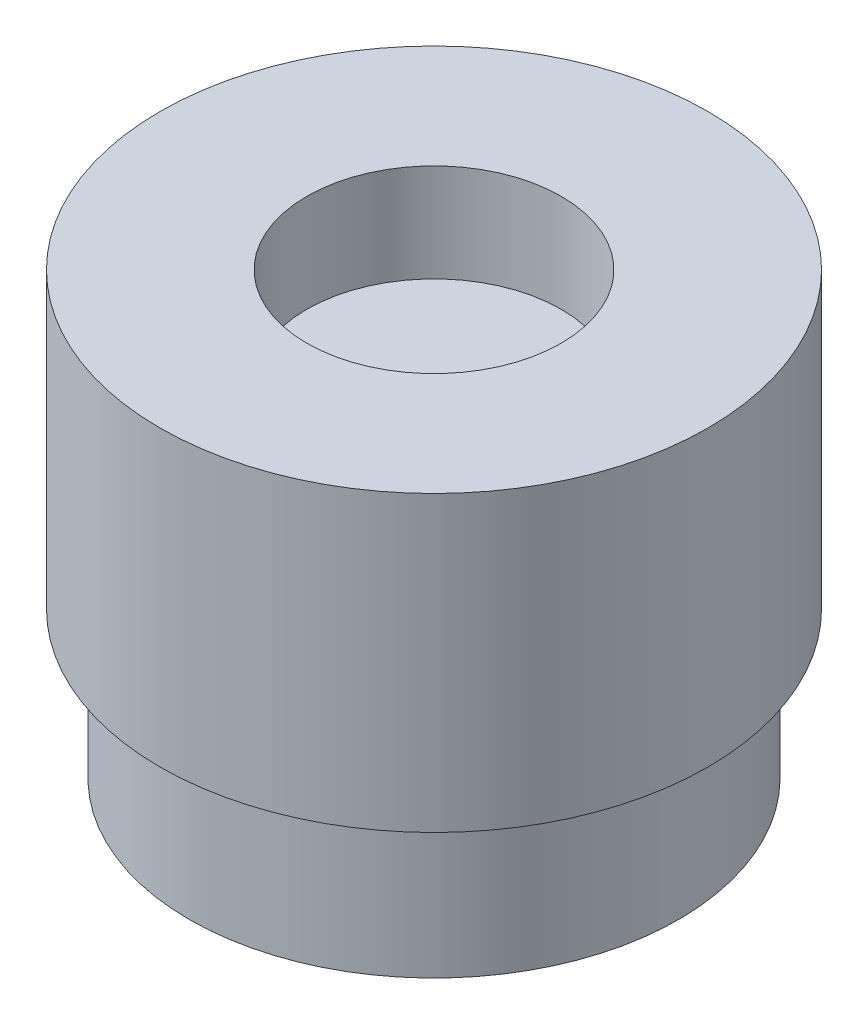
from build123d import *

# Parameters (mm, degrees)
SKETCH1_R           = 5
SKETCH1_R_2         = 1.5
BOSS_EXTRUDE1_DEPTH = 3
SKETCH3_R           = 4.5
SKETCH3_R_2         = 3.75
BOSS_EXTRUDE2_DEPTH = 2.5
SKETCH4_W           = 2
SKETCH4_H           = 1.385791926
CUT_EXTRUDE1_DEPTH  = 2.5
SKETCH5_R           = 5.6
BOSS_EXTRUDE3_DEPTH = 3
SKETCH6_R           = 5.6
BOSS_EXTRUDE4_DEPTH = 1
SKETCH7_R           = 5.6
SKETCH7_R_2         = 2.6
BOSS_EXTRUDE5_DEPTH = 2


with BuildPart() as part:
    # Sketch1 → Boss-Extrude1 (new body)
    with BuildSketch(Plane(origin=(0, 0, 0), x_dir=(1, 0, 0), z_dir=(0, 1, 0))):
        Circle(SKETCH1_R)
        Circle(SKETCH1_R_2, mode=Mode.SUBTRACT)
    extrude(amount=BOSS_EXTRUDE1_DEPTH)

    # Sketch3 → Boss-Extrude2 (add)
    with BuildSketch(Plane(origin=(0, 3, 0), x_dir=(1, 0, 0), z_dir=(0, 1, 0))):
        Circle(SKETCH3_R)
        Circle(SKETCH3_R_2, mode=Mode.SUBTRACT)
    extrude(amount=BOSS_EXTRUDE2_DEPTH)

    # Sketch4 → Cut-Extrude1 (cut)
    with BuildSketch(Plane(origin=(0, 5.5, 0), x_dir=(1, 0, 0), z_dir=(0, 1, 0))):
        with Locations((0, 4.307104037)):
            Rectangle(SKETCH4_W, SKETCH4_H)
    extrude(amount=-CUT_EXTRUDE1_DEPTH, mode=Mode.SUBTRACT)


with BuildPart() as body_2:
    # Sketch5 → Boss-Extrude3 (new body)
    with BuildSketch(Plane(origin=(0, 3, 0), x_dir=(1, 0, 0), z_dir=(0, 1, 0))):
        Circle(SKETCH5_R)
        with BuildLine():
            ThreePointArc((5, 0), (-3.181980515, -3.856812155), (-0.95, 4.908920452))
            Line((-0.95, 4.908920452), (-0.95, 5))
            Line((-0.95, 5), (0, 5))
            Line((0, 5), (0.95, 5))
            Line((0.95, 5), (0.95, 4.908920452))
            ThreePointArc((0.95, 4.908920452), (3.856812155, 3.181980515), (5, 0))
        make_face(mode=Mode.SUBTRACT)
        with BuildLine():
            ThreePointArc((4.6, 0), (-2.897412639, -3.572814017), (-0.95, 4.500833256))
            Line((-0.95, 4.500833256), (-0.95, 4.908920452))
            ThreePointArc((-0.95, 4.908920452), (-3.181980515, -3.856812155), (5, 0))
            ThreePointArc((5, 0), (3.856812155, 3.181980515), (0.95, 4.908920452))
            Line((0.95, 4.908920452), (0.95, 4.500833256))
            ThreePointArc((0.95, 4.500833256), (3.572814017, 2.897412639), (4.6, 0))
        make_face()
        with BuildLine():
            Line((-0.95, 4.908920452), (-0.95, 4.500833256))
            ThreePointArc((-0.95, 4.500833256), (0, 4.6), (0.95, 4.500833256))
            Line((0.95, 4.500833256), (0.95, 4.908920452))
            ThreePointArc((0.95, 4.908920452), (0.477178029, 4.977178029), (0, 5))
            ThreePointArc((0, 5), (-0.477178029, 4.977178029), (-0.95, 4.908920452))
        make_face()
        with BuildLine():
            Line((-0.95, 4.500833256), (-0.95, 3.75))
            Line((-0.95, 3.75), (0, 3.75))
            Line((0, 3.75), (0.95, 3.75))
            Line((0.95, 3.75), (0.95, 4.500833256))
            ThreePointArc((0.95, 4.500833256), (0, 4.6), (-0.95, 4.500833256))
        make_face()
        with BuildLine():
            Line((-0.95, 5), (-0.95, 4.908920452))
            ThreePointArc((-0.95, 4.908920452), (-0.477178029, 4.977178029), (0, 5))
            Line((0, 5), (-0.95, 5))
        make_face()
        with BuildLine():
            Line((0.95, 5), (0, 5))
            ThreePointArc((0, 5), (0.477178029, 4.977178029), (0.95, 4.908920452))
            Line((0.95, 4.908920452), (0.95, 5))
        make_face()
    extrude(amount=BOSS_EXTRUDE3_DEPTH)

    # Sketch6 → Boss-Extrude4 (add)
    with BuildSketch(Plane(origin=(0, 6, 0), x_dir=(1, 0, 0), z_dir=(0, 1, 0))):
        Circle(SKETCH6_R)
    extrude(amount=BOSS_EXTRUDE4_DEPTH)

    # Sketch7 → Boss-Extrude5 (add)
    with BuildSketch(Plane(origin=(0, 7, 0), x_dir=(1, 0, 0), z_dir=(0, 1, 0))):
        Circle(SKETCH7_R)
        Circle(SKETCH7_R_2, mode=Mode.SUBTRACT)
    extrude(amount=BOSS_EXTRUDE5_DEPTH)


solid = Compound([part.part, body_2.part])
